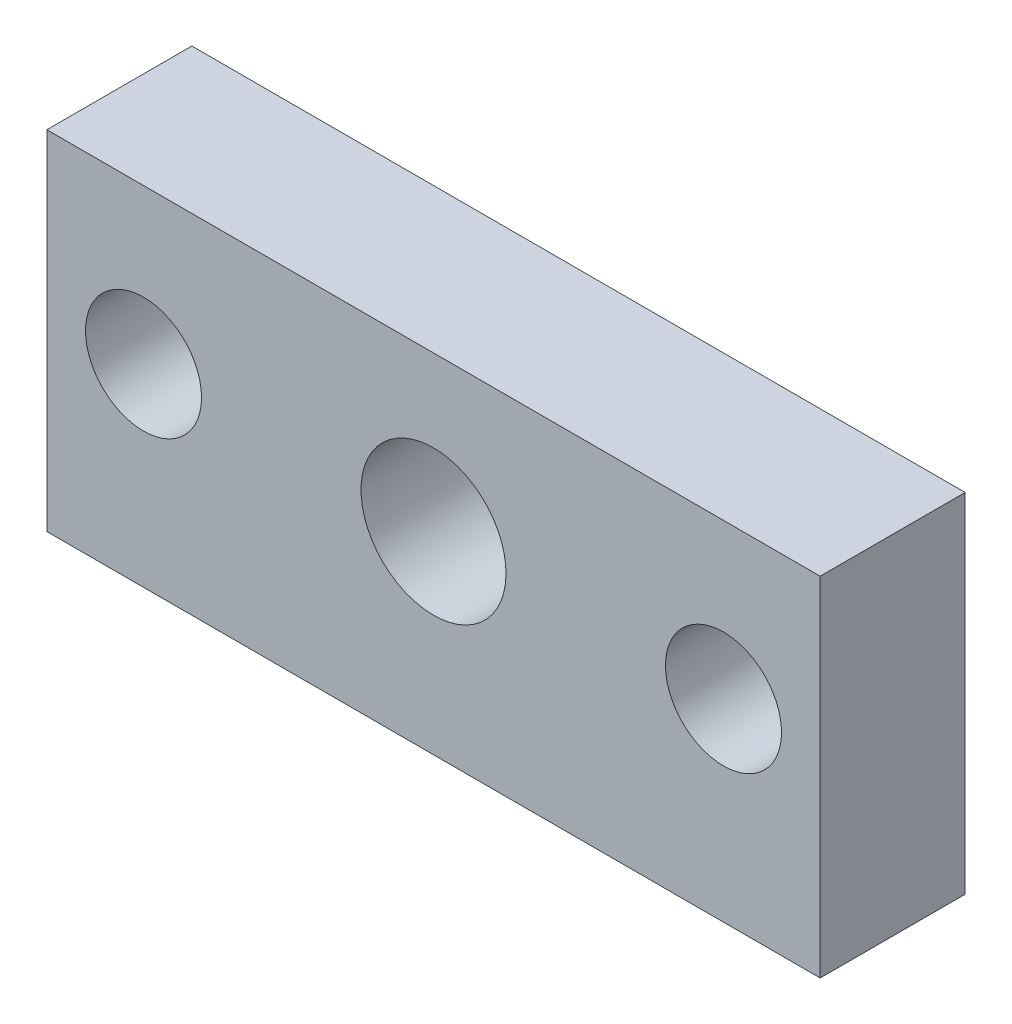
from build123d import *

# Parameters (mm, degrees)
SKETCH_1_W      = 80
SKETCH_1_H      = 36
SKETCH_1_R      = 6
SKETCH_1_R_2    = 7.5
EXTRUDE_1_DEPTH = 15


with BuildPart() as part:
    # 草图1 → 凸台-拉伸1 (new body)
    with BuildSketch(Plane.XY):
        with Locations((9.333333333, 2.888888889)):
            Rectangle(SKETCH_1_W, SKETCH_1_H)
        with Locations((-20.666666667, 4.888888889)):
            Circle(SKETCH_1_R, mode=Mode.SUBTRACT)
        with Locations((9.333333333, 4.888888889)):
            Circle(SKETCH_1_R_2, mode=Mode.SUBTRACT)
        with Locations((39.333333333, 4.888888889)):
            Circle(SKETCH_1_R, mode=Mode.SUBTRACT)
    extrude(amount=EXTRUDE_1_DEPTH)


solid = part.part
